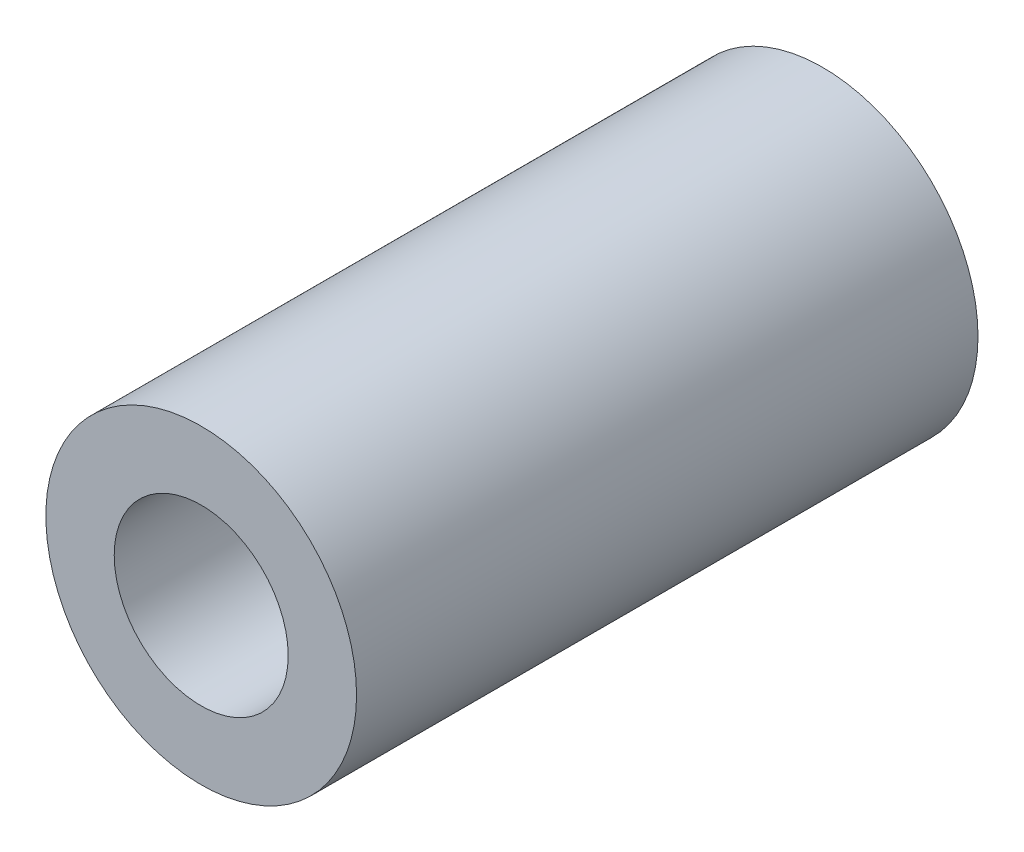
from build123d import *

# Parameters (mm, degrees)
SKETCH1_R      = 3.175
SKETCH1_R_2    = 1.778
EXTRUDE1_DEPTH = 6.35


with BuildPart() as part:
    # Sketch1 → Extrude1 (new body, symmetric)
    with BuildSketch(Plane.XY):
        Circle(SKETCH1_R)
        Circle(SKETCH1_R_2, mode=Mode.SUBTRACT)
    extrude(amount=EXTRUDE1_DEPTH, both=True)


solid = part.part
